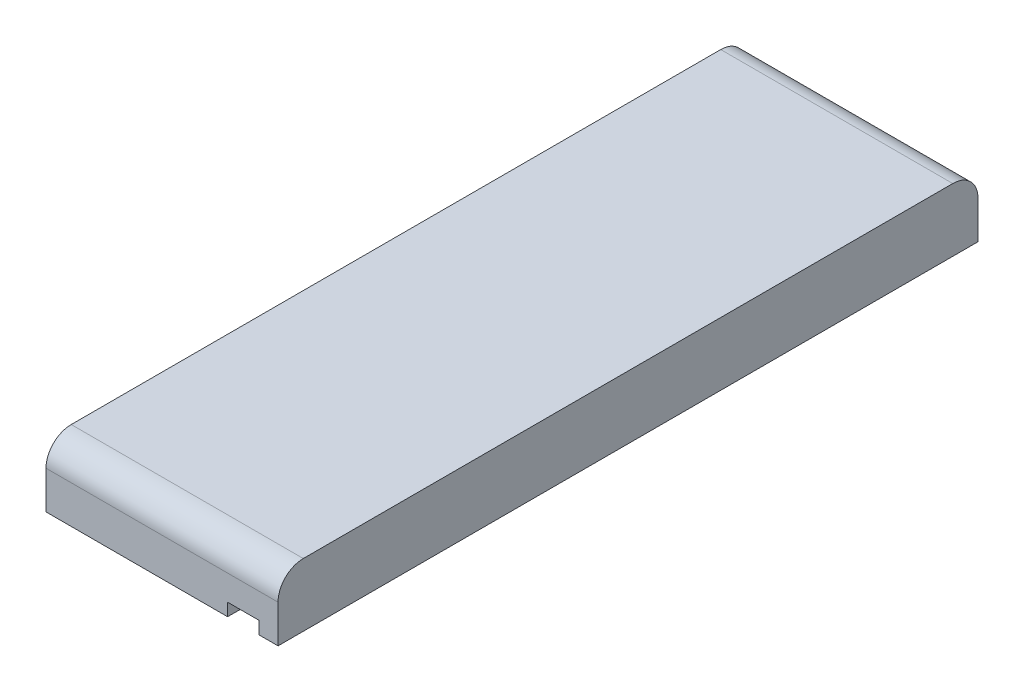
from build123d import *

# Parameters (mm, degrees)
SKETCH1_W                       = 18.4
SKETCH1_H                       = 5
BOSS_EXTRUDE1_DEPTH             = 55.5
SKETCH2_W                       = 2.5
SKETCH2_H                       = 1
CUT_EXTRUDE1_DEPTH              = 56.5
M2X0_4_TAPPED_HOLE1_D           = 1.6
M2X0_4_TAPPED_HOLE1_DEPTH       = 7
M2X0_4_TAPPED_HOLE1_CBORE_D     = 2
M2X0_4_TAPPED_HOLE1_CBORE_DEPTH = 5
M2X0_4_TAPPED_HOLE1_TIP         = 0.480688495
FILLET1_R                       = 2


with BuildPart() as part:
    # Sketch1 → Boss-Extrude1 (new body)
    with BuildSketch(Plane.XY):
        with Locations((-9.2, 2.5)):
            Rectangle(SKETCH1_W, SKETCH1_H)
    extrude(amount=BOSS_EXTRUDE1_DEPTH)

    # Sketch2 → Cut-Extrude1 (cut, through all)
    with BuildSketch(Plane.XY.offset(55.5)):
        with Locations((-2.75, 0.5)):
            Rectangle(SKETCH2_W, SKETCH2_H)
    extrude(amount=-CUT_EXTRUDE1_DEPTH, mode=Mode.SUBTRACT)

    # M2x0.4 Tapped Hole1
    with Locations(Plane.ZY.offset(18.4)):
        with Locations((51.75, 3), (27.75, 3), (3.75, 3)):
            CounterBoreHole(M2X0_4_TAPPED_HOLE1_D / 2, M2X0_4_TAPPED_HOLE1_CBORE_D / 2, M2X0_4_TAPPED_HOLE1_CBORE_DEPTH, depth=M2X0_4_TAPPED_HOLE1_DEPTH)
            with Locations((0, 0, -(M2X0_4_TAPPED_HOLE1_DEPTH + M2X0_4_TAPPED_HOLE1_TIP / 2))):  # 118° drill point
                Cone(0, M2X0_4_TAPPED_HOLE1_D / 2, M2X0_4_TAPPED_HOLE1_TIP, mode=Mode.SUBTRACT)

    # Fillet1
    fillet1_edges = [part.edges().sort_by_distance(p)[0] for p in [
        (-9.2, 5, 0),
        (-9.2, 5, 55.5),
    ]]
    fillet(fillet1_edges, radius=FILLET1_R)


solid = part.part
